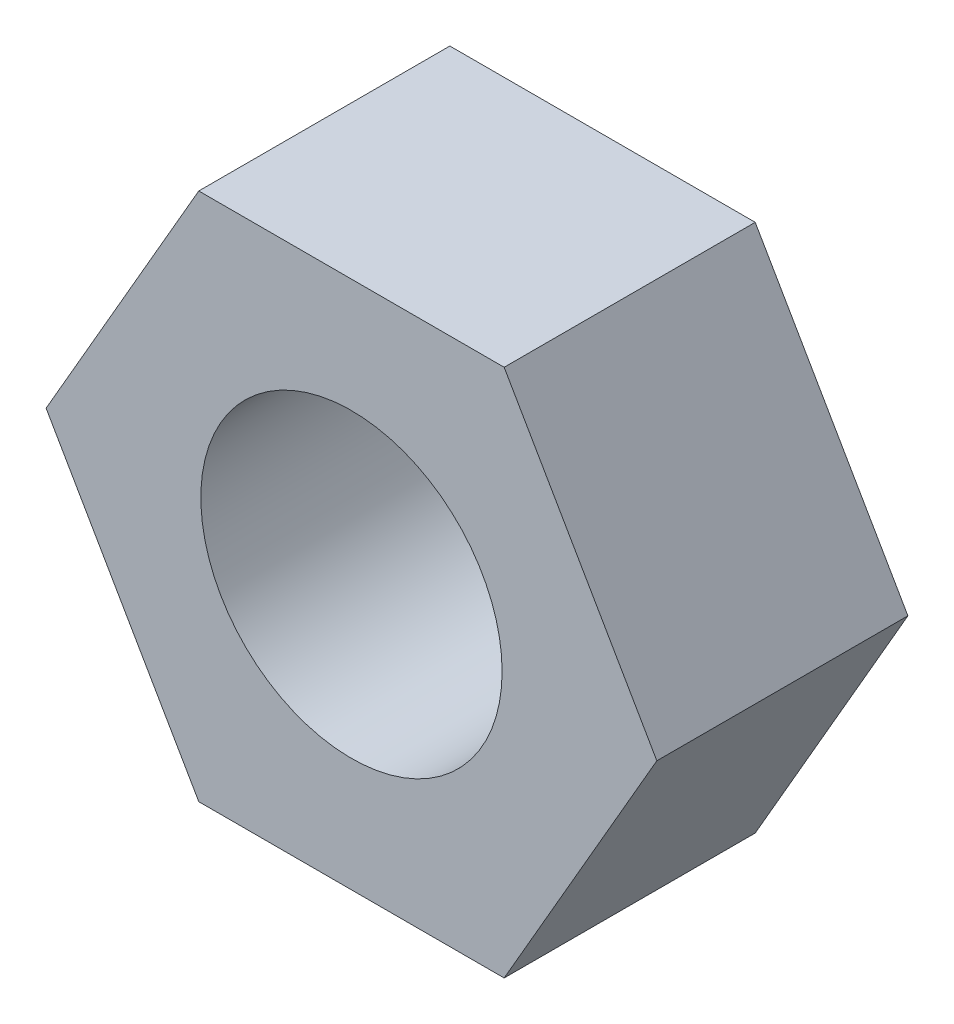
from build123d import *

# Parameters (mm, degrees)
BOSS_EXTRUDE1_DEPTH = 3.75
SKETCH2_R           = 2.25
CUT_EXTRUDE1_DEPTH  = 4.75


with BuildPart() as part:
    # Sketch1 → Boss-Extrude1 (new body)
    with BuildSketch(Plane.XY):
        Polygon((2.280533563, 3.95), (-2.280533563, 3.95), (-4.561067127, 0), (-2.280533563, -3.95), (2.280533563, -3.95), (4.561067127, 0), align=None)
    extrude(amount=BOSS_EXTRUDE1_DEPTH)

    # Sketch2 → Cut-Extrude1 (cut, through all)
    with BuildSketch(Plane.XY.offset(3.75)):
        Circle(SKETCH2_R)
    extrude(amount=-CUT_EXTRUDE1_DEPTH, mode=Mode.SUBTRACT)


solid = part.part
